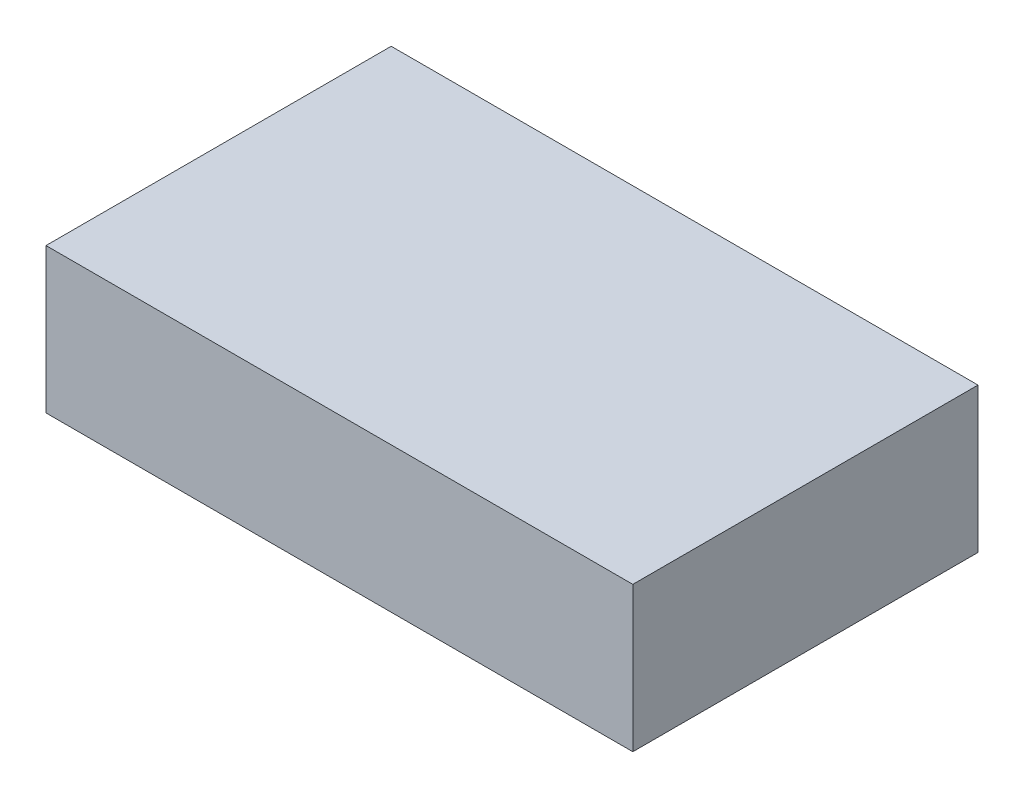
from build123d import *

# Parameters (mm, degrees)
SKETCH2_W           = 85
SKETCH2_H           = 50
BOSS_EXTRUDE1_DEPTH = 10.5


with BuildPart() as part:
    # Sketch2 → Boss-Extrude1 (new body, symmetric)
    with BuildSketch(Plane(origin=(0, 0, 0), x_dir=(1, 0, 0), z_dir=(0, 1, 0))):
        Rectangle(SKETCH2_W, SKETCH2_H)
    extrude(amount=BOSS_EXTRUDE1_DEPTH, both=True)


solid = part.part
